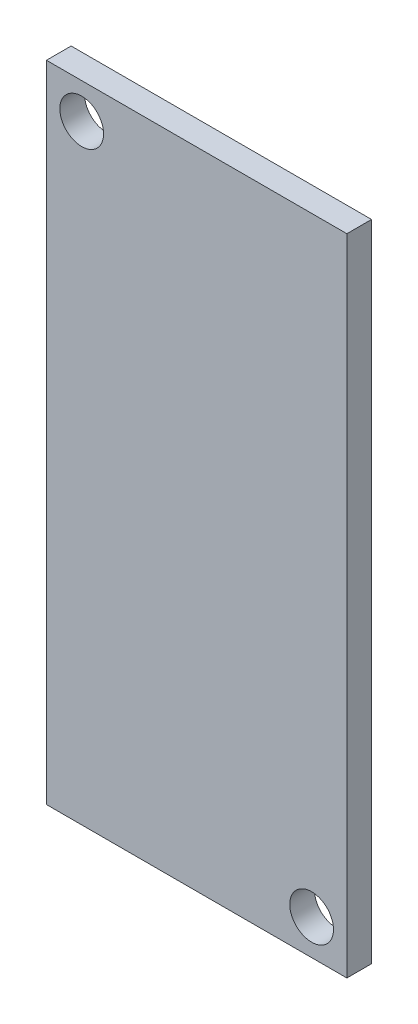
from build123d import *

# Parameters (mm, degrees)
SKETCH1_W          = 21.3
SKETCH1_H          = 45.7
EXTRUDE1_DEPTH     = 1.75
SKETCH2_R          = 1.55
CUT_EXTRUDE1_DEPTH = 1.75


with BuildPart() as part:
    # Sketch1 → Extrude1 (new body)
    with BuildSketch(Plane.XY):
        Rectangle(SKETCH1_W, SKETCH1_H)
    extrude(amount=EXTRUDE1_DEPTH)

    # Sketch2 → Cut-Extrude1 (cut)
    with BuildSketch(Plane.XY.offset(1.75)):
        with Locations((8.15, -20.35)):
            Circle(SKETCH2_R)
        with Locations((-8.15, 20.35)):
            Circle(SKETCH2_R)
    extrude(amount=-CUT_EXTRUDE1_DEPTH, mode=Mode.SUBTRACT)


solid = part.part
